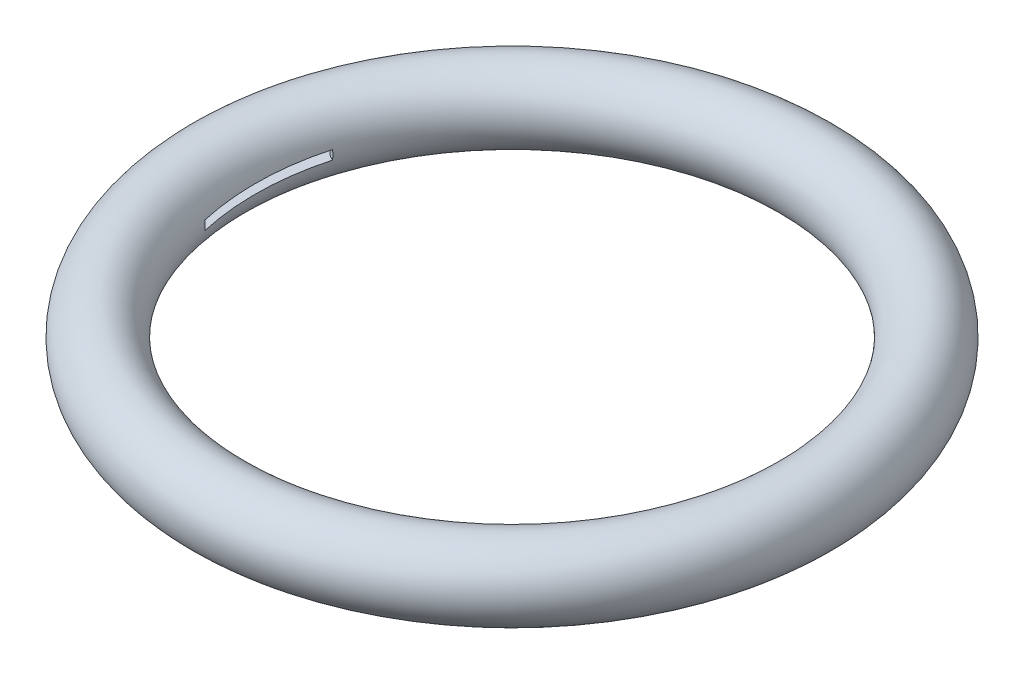
from build123d import *

# Parameters (mm, degrees)
SKETCH1_R          = 12.7
SKETCH3_R          = 107.95
CUT_EXTRUDE1_DEPTH = 1.5875


with BuildPart() as part:
    # Sketch1 → Revolve1 (revolve)
    with BuildSketch(Plane.XY):
        with Locations((101.6, 0)):
            Circle(SKETCH1_R)
    revolve(axis=Axis((0, 3.175, 0), (0, -1, 0)))

    # Sketch3 → Cut-Extrude1 (cut, symmetric)
    with BuildSketch(Plane(origin=(0, 0, 0), x_dir=(1, 0, 0), z_dir=(0, 1, 0))):
        Circle(SKETCH3_R)
        with BuildLine():
            ThreePointArc((27.757566502, -91.11575057), (67.351920908, -67.351920908), (91.11575057, -27.757566502))
            ThreePointArc((91.11575057, -27.757566502), (89.903527616, -21.822714376), (84.266922058, -19.60446461))
            ThreePointArc((84.266922058, -19.60446461), (40.804807613, -40.804807613), (19.60446461, -84.266922058))
            ThreePointArc((19.60446461, -84.266922058), (21.822714376, -89.903527616), (27.757566502, -91.11575057))
        make_face(mode=Mode.SUBTRACT)
        with BuildLine():
            ThreePointArc((-81.63869201, 23.668181818), (0, 38.1), (81.63869201, 23.668181818))
            ThreePointArc((81.63869201, 23.668181818), (88.283116885, 25.120584837), (89.802561211, 31.75))
            ThreePointArc((89.802561211, 31.75), (0, 95.25), (-89.802561211, 31.75))
            ThreePointArc((-89.802561211, 31.75), (-88.283116885, 25.120584837), (-81.63869201, 23.668181818))
        make_face(mode=Mode.SUBTRACT)
        with BuildLine():
            ThreePointArc((-84.266922058, -19.60446461), (-40.804807613, -40.804807613), (-19.60446461, -84.266922058))
            ThreePointArc((-19.60446461, -84.266922058), (-21.822714376, -89.903527616), (-27.757566502, -91.11575057))
            ThreePointArc((-27.757566502, -91.11575057), (-67.351920908, -67.351920908), (-91.11575057, -27.757566502))
            ThreePointArc((-91.11575057, -27.757566502), (-89.903527616, -21.822714376), (-84.266922058, -19.60446461))
        make_face(mode=Mode.SUBTRACT)
    extrude(amount=CUT_EXTRUDE1_DEPTH, both=True, mode=Mode.SUBTRACT)


solid = part.part
